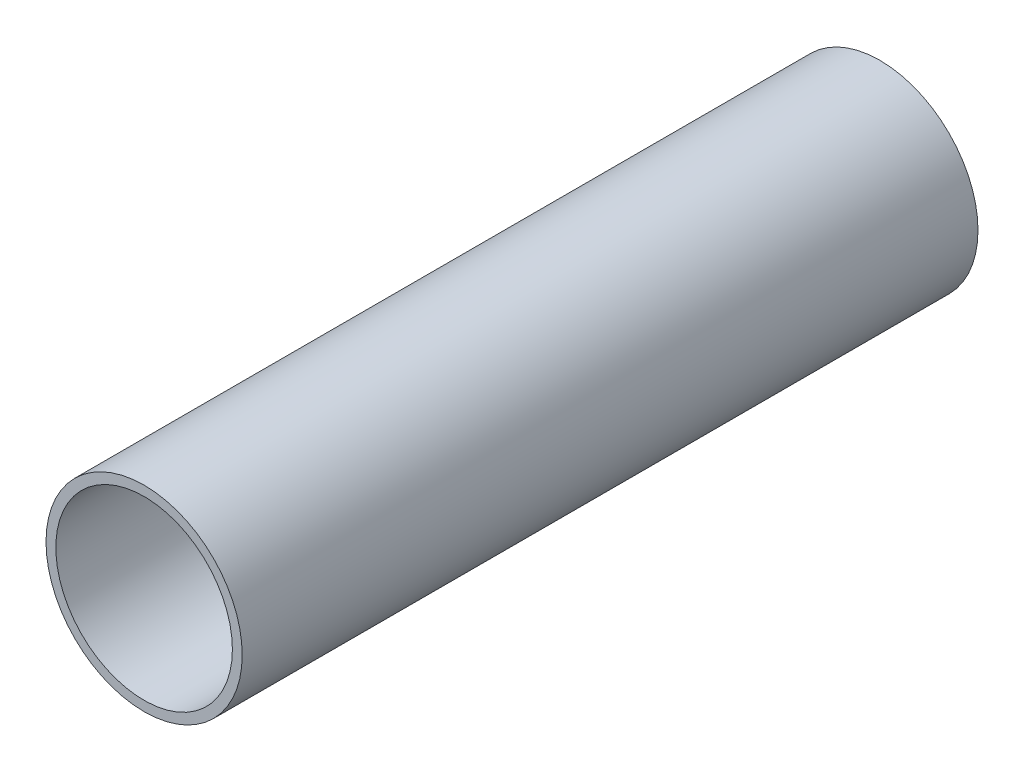
from build123d import *

# Parameters (mm, degrees)
SKETCH2_R           = 20
SKETCH2_R_2         = 18
BOSS_EXTRUDE1_DEPTH = 150


with BuildPart() as part:
    # Sketch2 → Boss-Extrude1 (new body)
    with BuildSketch(Plane.XY):
        Circle(SKETCH2_R)
        Circle(SKETCH2_R_2, mode=Mode.SUBTRACT)
    extrude(amount=BOSS_EXTRUDE1_DEPTH)


solid = part.part
